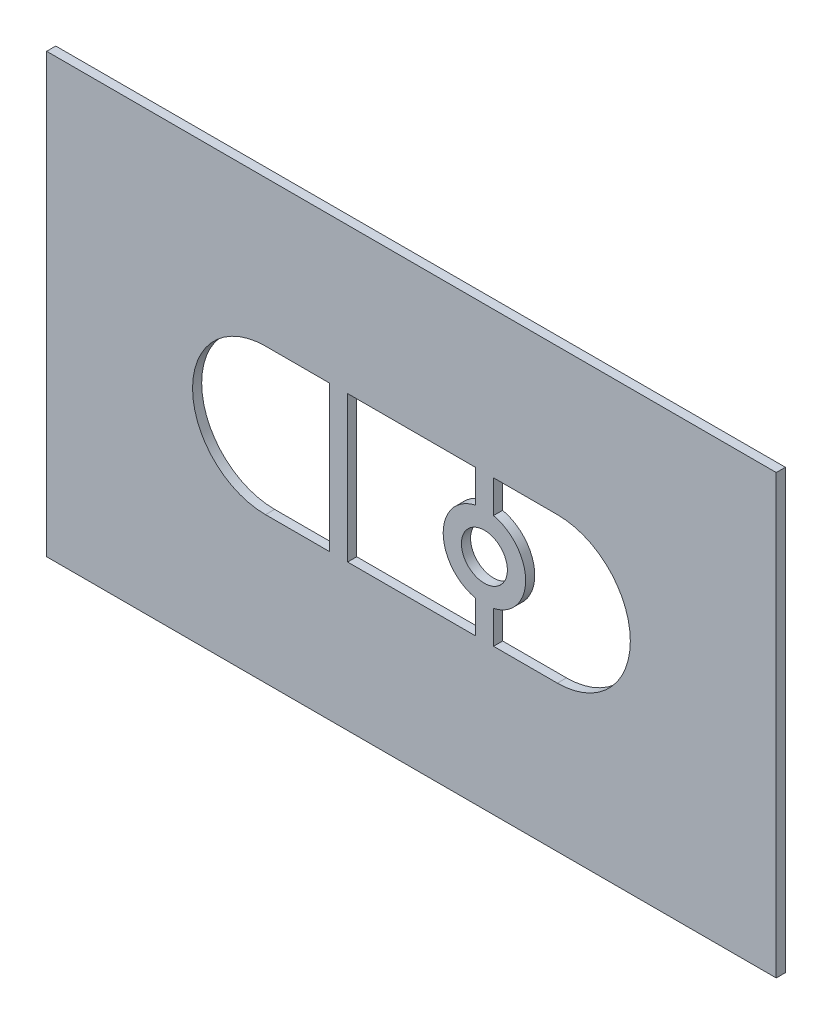
from build123d import *

# Parameters (mm, degrees)
SKETCH1_W           = 127
SKETCH1_H           = 76.2
SKETCH1_R           = 4
BOSS_EXTRUDE1_DEPTH = 1.5875


with BuildPart() as part:
    # Sketch1 → Boss-Extrude1 (new body)
    with BuildSketch(Plane.XY):
        with Locations((63.5, 38.1)):
            Rectangle(SKETCH1_W, SKETCH1_H)
        with Locations((76.2, 38.1)):
            Circle(SKETCH1_R, mode=Mode.SUBTRACT)
        with BuildLine():
            Line((38.1, 50.8), (49.2125, 50.8))
            Line((49.2125, 50.8), (49.2125, 25.4))
            Line((49.2125, 25.4), (38.1, 25.4))
            ThreePointArc((38.1, 25.4), (25.4, 38.1), (38.1, 50.8))
        make_face(mode=Mode.SUBTRACT)
        with BuildLine():
            Line((88.9, 25.4), (77.7875, 25.4))
            Line((77.7875, 25.4), (77.7875, 31.10282423))
            ThreePointArc((77.7875, 31.10282423), (83.375, 38.1), (77.7875, 45.09717577))
            Line((77.7875, 45.09717577), (77.7875, 50.8))
            Line((77.7875, 50.8), (88.9, 50.8))
            ThreePointArc((88.9, 50.8), (101.6, 38.1), (88.9, 25.4))
        make_face(mode=Mode.SUBTRACT)
        with BuildLine():
            Line((52.3875, 50.8), (74.6125, 50.8))
            Line((74.6125, 50.8), (74.6125, 45.09717577))
            ThreePointArc((74.6125, 45.09717577), (69.025, 38.1), (74.6125, 31.10282423))
            Line((74.6125, 31.10282423), (74.6125, 25.4))
            Line((74.6125, 25.4), (52.3875, 25.4))
            Line((52.3875, 25.4), (52.3875, 50.8))
        make_face(mode=Mode.SUBTRACT)
    extrude(amount=BOSS_EXTRUDE1_DEPTH)


solid = part.part
